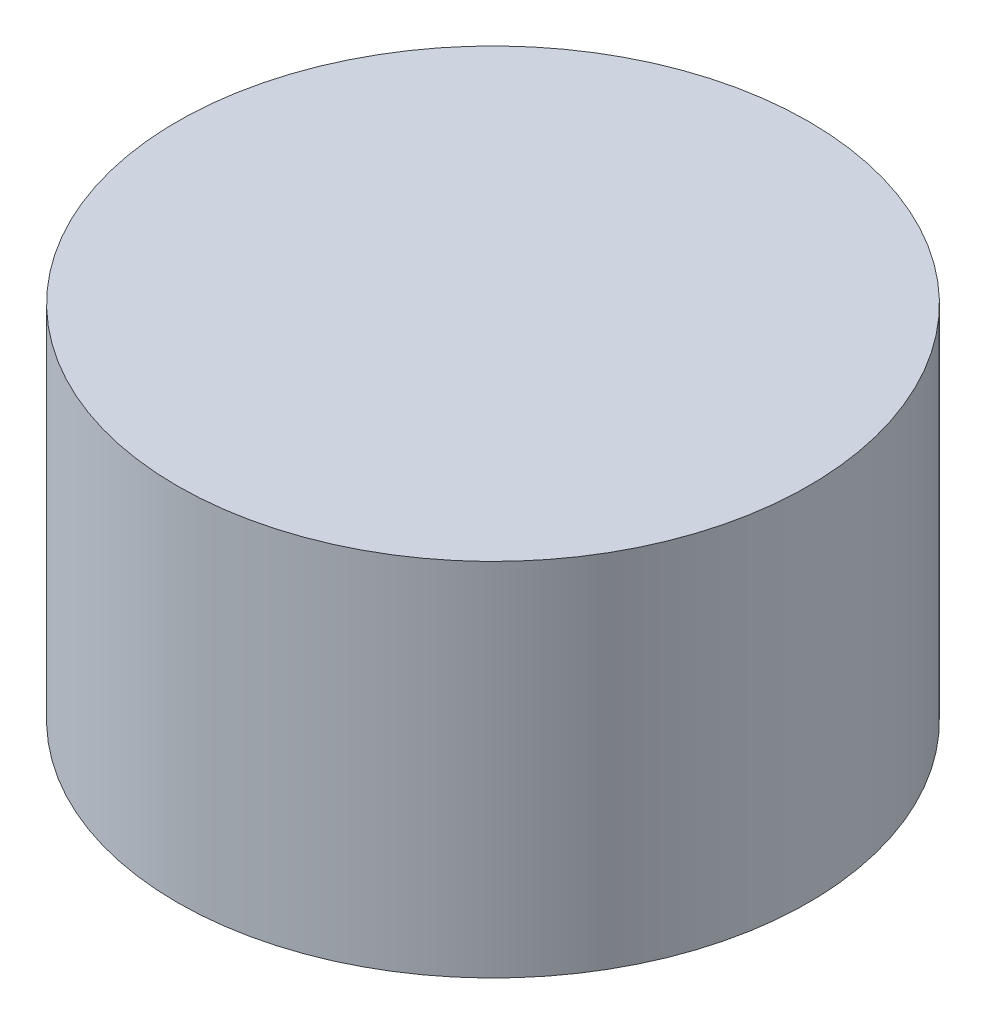
from build123d import *

# Parameters (mm, degrees)
ESBO_O1_R                = 45.5
RESSALTO_EXTRUS_O1_DEPTH = 2
ESBO_O2_R                = 45.5
ESBO_O2_R_2              = 43.5
RESSALTO_EXTRUS_O2_DEPTH = 50


with BuildPart() as part:
    # Esboço1 → Ressalto-extrusão1 (new body)
    with BuildSketch(Plane(origin=(0, 0, 0), x_dir=(1, 0, 0), z_dir=(0, 1, 0))):
        Circle(ESBO_O1_R)
    extrude(amount=RESSALTO_EXTRUS_O1_DEPTH)

    # Esboço2 → Ressalto-extrusão2 (add)
    with BuildSketch(Plane.XZ):
        Circle(ESBO_O2_R)
        Circle(ESBO_O2_R_2, mode=Mode.SUBTRACT)
    extrude(amount=RESSALTO_EXTRUS_O2_DEPTH)


solid = part.part
